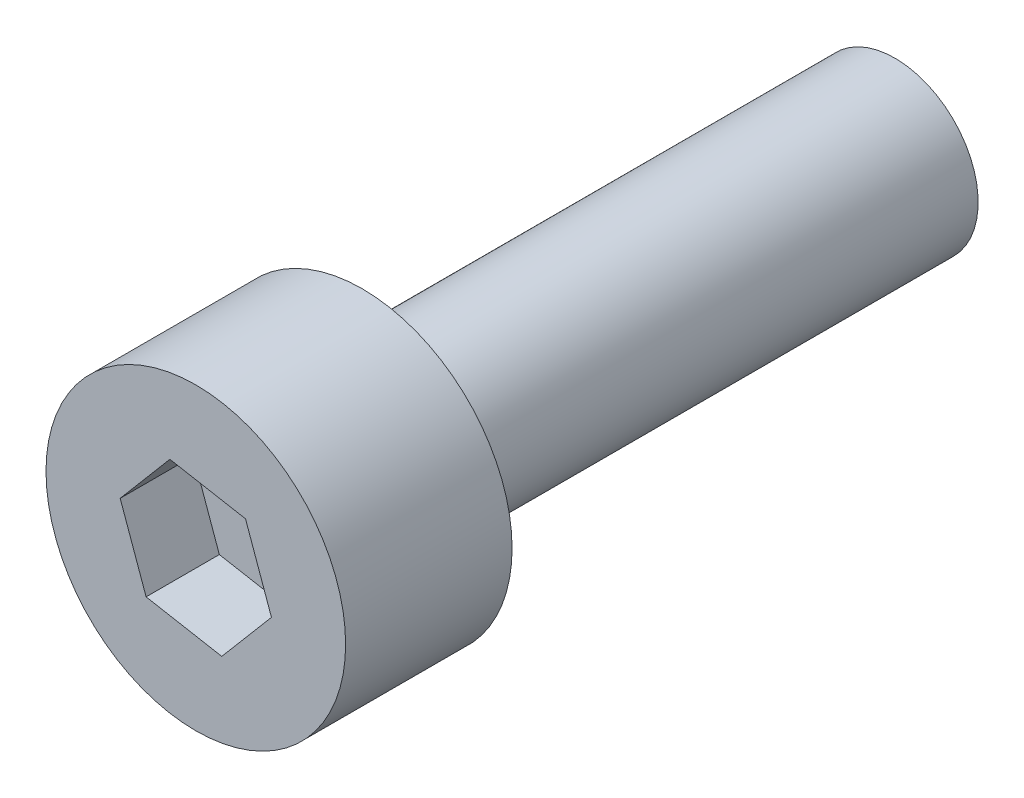
from build123d import *

# Parameters (mm, degrees)
SKETCH_1_R          = 2.25
EXTRUDE_1_DEPTH     = 2.5
CUT_EXTRUDE_1_DEPTH = 1.1
SKETCH_3_R          = 1.25
EXTRUDE_2_DEPTH     = 8


with BuildPart() as part:
    # 草图1 → 凸台-拉伸1 (new body)
    with BuildSketch(Plane.XY):
        Circle(SKETCH_1_R)
    extrude(amount=EXTRUDE_1_DEPTH)

    # 草图2 → 切除-拉伸1 (cut)
    with BuildSketch(Plane.XY.offset(2.5)):
        Polygon((-0.746595952, -0.880867651), (0.389555787, -1.087004886), (1.136151739, -0.206137235), (0.746595952, 0.880867651), (-0.389555787, 1.087004886), (-1.136151739, 0.206137235), align=None)
    extrude(amount=-CUT_EXTRUDE_1_DEPTH, mode=Mode.SUBTRACT)

    # 草图3 → 凸台-拉伸2 (add)
    with BuildSketch(Plane(origin=(0, 0, 0), x_dir=(-1, 0, 0), z_dir=(0, 0, -1))):
        Circle(SKETCH_3_R)
    extrude(amount=EXTRUDE_2_DEPTH)


solid = part.part
